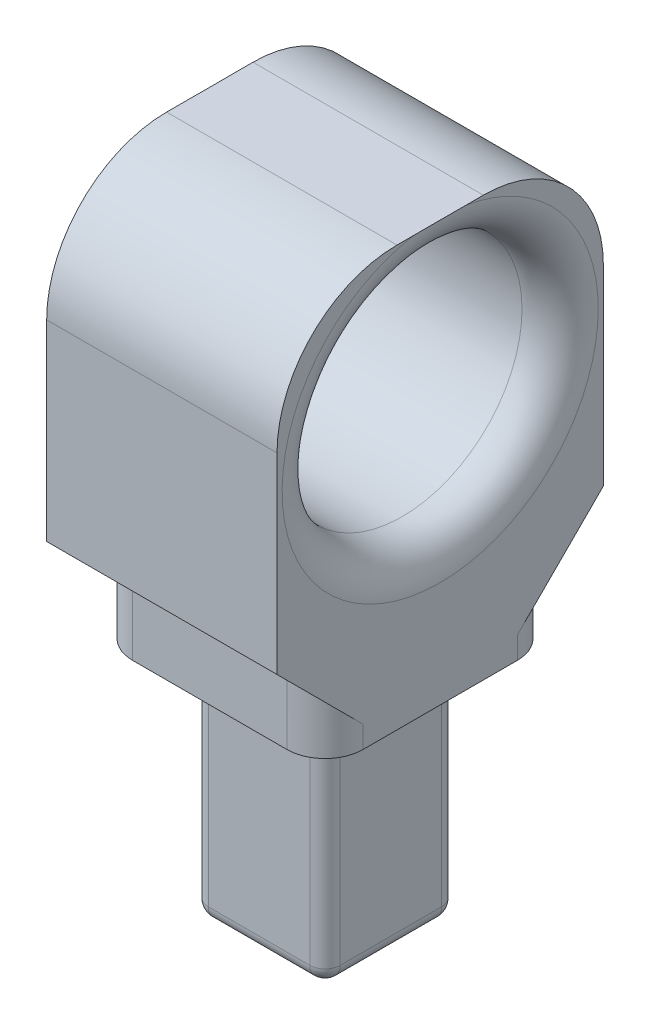
from build123d import *

# Parameters (mm, degrees)
SKETCH1_W           = 35
SKETCH1_H           = 27.2
BOSS_EXTRUDE1_DEPTH = 19.2
SKETCH2_W           = 4
SKETCH2_H           = 5
CUT_EXTRUDE1_DEPTH  = 20.2
SKETCH3_W           = 4
SKETCH3_H           = 5
CUT_EXTRUDE2_DEPTH  = 20.2
SKETCH4_W           = 11
SKETCH4_H           = 11
BOSS_EXTRUDE2_DEPTH = 20
DRAFT1_ANGLE        = 45
DRAFT2_ANGLE        = 45
FILLET1_R           = 1.27
FILLET2_R           = 3.175
FILLET3_R           = 10


with BuildPart() as part:
    # Sketch1 → Boss-Extrude1 (new body)
    with BuildSketch(Plane(origin=(-15.2, 0, 0), x_dir=(0, -1, 0), z_dir=(-1, 0, 0))):
        with Locations((-37.5, -5.6)):
            Rectangle(SKETCH1_W, SKETCH1_H)
    extrude(amount=-BOSS_EXTRUDE1_DEPTH)

    # Sketch2 → Cut-Extrude1 (cut, through all)
    with BuildSketch(Plane(origin=(4, 0, 0), x_dir=(0, 0, -1), z_dir=(1, 0, 0))):
        with Locations((-6, 22.5)):
            Rectangle(SKETCH2_W, SKETCH2_H)
    extrude(amount=-CUT_EXTRUDE1_DEPTH, mode=Mode.SUBTRACT)

    # Sketch3 → Cut-Extrude2 (cut, through all)
    with BuildSketch(Plane(origin=(4, 0, 0), x_dir=(0, 0, -1), z_dir=(1, 0, 0))):
        with Locations((17.2, 22.5)):
            Rectangle(SKETCH3_W, SKETCH3_H)
    extrude(amount=-CUT_EXTRUDE2_DEPTH, mode=Mode.SUBTRACT)

    # Sketch4 → Boss-Extrude2 (add)
    with BuildSketch(Plane.XZ.offset(-20)):
        with Locations((-5.6, -5.6)):
            Rectangle(SKETCH4_W, SKETCH4_H)
    extrude(amount=BOSS_EXTRUDE2_DEPTH)

    # Draft1
    draft1_faces = [part.faces().sort_by_distance(p)[0] for p in [
        (-5.6, 25, 6),
    ]]
    draft(draft1_faces, Plane(origin=(-15.2, 20, 4), x_dir=(1, 0, 0), z_dir=(0, 0, 1)), DRAFT1_ANGLE)

    # Draft2
    draft2_faces = [part.faces().sort_by_distance(p)[0] for p in [
        (-5.6, 25, -17.2),
    ]]
    draft(draft2_faces, Plane(origin=(-15.2, 25, -15.2), x_dir=(0, -1, 0), z_dir=(0, 0, -1)), DRAFT2_ANGLE)

    # Sketch5 → Cut-Revolve1 (revolve, cut)
    with BuildSketch(Plane.XY.offset(-5.6)):
        with BuildLine():
            Line((-15.2, 55.175), (-15.2, 42))
            Line((-15.2, 42), (4, 42))
            Line((4, 42), (4, 55.175))
            ThreePointArc((4, 55.175), (3.07006403, 52.92993597), (0.825, 52))
            Line((0.825, 52), (-12.025, 52))
            ThreePointArc((-12.025, 52), (-14.27006403, 52.92993597), (-15.2, 55.175))
        make_face()
    revolve(axis=Axis((-15.2, 42, -5.6), (1, 0, 0)), mode=Mode.SUBTRACT)

    # Fillet1
    fillet1_edges = [part.edges().sort_by_distance(p)[0] for p in [
        (-0.1, 10, -11.1),
        (-0.1, 10, -0.1),
        (-11.1, 10, -0.1),
        (-11.1, 10, -11.1),
        (-0.1, 0, -5.6),
        (-5.6, 0, -0.1),
        (-11.1, 0, -5.6),
        (-5.6, 0, -11.1),
    ]]
    fillet(fillet1_edges, radius=FILLET1_R)

    # Fillet2
    fillet2_edges = [part.edges().sort_by_distance(p)[0] for p in [
        (-15.2, 22.5, 4),
        (4, 22.5, 4),
        (-15.2, 22.5, -15.2),
        (4, 22.5, -15.2),
    ]]
    fillet(fillet2_edges, radius=FILLET2_R)

    # Fillet3
    fillet3_edges = [part.edges().sort_by_distance(p)[0] for p in [
        (-5.6, 55, 8),
        (-5.6, 55, -19.2),
    ]]
    fillet(fillet3_edges, radius=FILLET3_R)


solid = part.part
